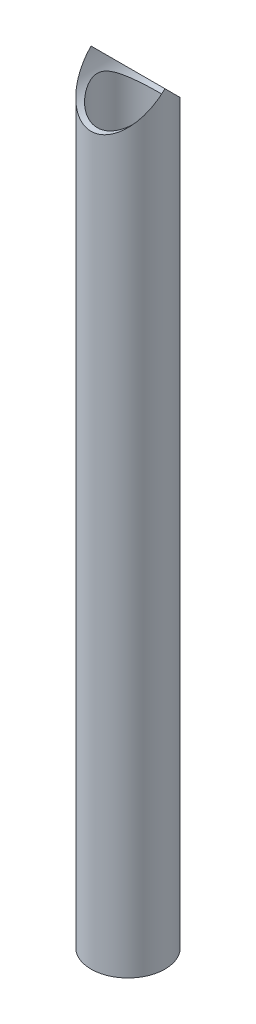
from build123d import *

# Parameters (mm, degrees)
SKETCH1_R               = 21.082
SKETCH1_R_2             = 17.526
BOSS_EXTRUDE1_DEPTH     = 434.975
SKETCH2_R               = 21.082
CUT_EXTRUDE1_DEPTH      = 22.082
CUT_EXTRUDE1_DEPTH_BACK = 22.082


with BuildPart() as part:
    # Sketch1 → Boss-Extrude1 (new body)
    with BuildSketch(Plane(origin=(0, 0, 0), x_dir=(1, 0, 0), z_dir=(0, 1, 0))):
        Circle(SKETCH1_R)
        Circle(SKETCH1_R_2, mode=Mode.SUBTRACT)
    extrude(amount=BOSS_EXTRUDE1_DEPTH)

    # Sketch2 → Cut-Extrude1 (cut, two sides)
    with BuildSketch(Plane.XY) as cut_extrude1_sk:
        with Locations((0, 434.975)):
            Circle(SKETCH2_R)
    extrude(amount=CUT_EXTRUDE1_DEPTH, mode=Mode.SUBTRACT)
    extrude(cut_extrude1_sk.sketch, amount=-CUT_EXTRUDE1_DEPTH_BACK, mode=Mode.SUBTRACT)


solid = part.part
